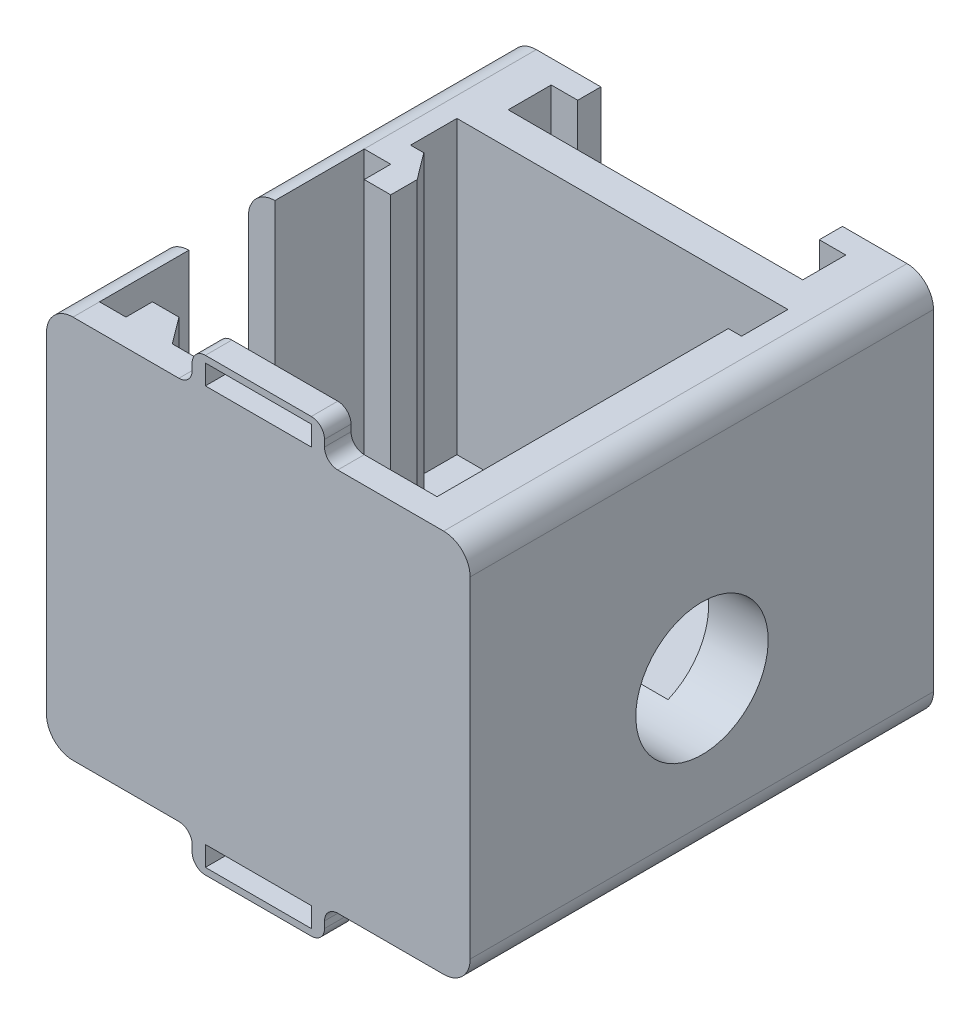
from build123d import *

# Parameters (mm, degrees)
SKETCH1_W                = 32
SKETCH1_H                = 29
BOSS_EXTRUDE1_DEPTH      = 35
FILLET1_R                = 2
SLOT_FOR_COIL_DEPTH      = 1
SLOT_FOR_COIL_DEPTH_BACK = 30
BOSS_EXTRUDE2_DEPTH      = 7
BOSS_EXTRUDE3_DEPTH      = 1.75
SKETCH5_W                = 2
SKETCH5_H                = 7
CUT_EXTRUDE2_DEPTH       = 33
CUT_EXTRUDE3_DEPTH       = 22
SKETCH7_W                = 2
SKETCH7_H                = 33
BOSS_EXTRUDE4_DEPTH      = 0.25
FILLET2_R                = 6
CUT_EXTRUDE5_DEPTH       = 4.5
SKETCH14_W               = 2.5
SKETCH14_H               = 20
CUT_EXTRUDE6_DEPTH       = 22
SKETCH16_W               = 2
SKETCH16_H               = 2
BOSS_EXTRUDE5_DEPTH      = 22
BOSS_EXTRUDE6_DEPTH      = 22
SKETCH21_W               = 10
SKETCH21_H               = 2
BOSS_EXTRUDE7_DEPTH      = 2.5
SKETCH23_W               = 8
SKETCH23_H               = 1.5
CUT_EXTRUDE7_DEPTH       = 2
FILLET3_R                = 1
CUT_EXTRUDE8_REACH       = 34
SKETCH26_R               = 5


with BuildPart() as part:
    # Sketch1 → Boss-Extrude1 (new body)
    with BuildSketch(Plane.XY):
        Rectangle(SKETCH1_W, SKETCH1_H)
    extrude(amount=BOSS_EXTRUDE1_DEPTH)

    # Fillet1
    fillet1_edges = [part.edges().sort_by_distance(p)[0] for p in [
        (16, -14.5, 17.5),
        (-16, -14.5, 17.5),
        (-16, 14.5, 17.5),
        (16, 14.5, 17.5),
    ]]
    fillet(fillet1_edges, radius=FILLET1_R)

    # Sketch2 → Slot for Coil (cut, two sides)
    with BuildSketch(Plane.XZ.offset(14.5)) as slot_for_coil_sk:
        Polygon((-9.125, 0), (-9.125, 1.75), (-11.125, 1.75), (-11.125, 5), (11.125, 5), (11.125, 1.75), (9.125, 1.75), (9.125, 0), align=None)
    extrude(amount=SLOT_FOR_COIL_DEPTH, mode=Mode.SUBTRACT)
    extrude(slot_for_coil_sk.sketch, amount=-SLOT_FOR_COIL_DEPTH_BACK, mode=Mode.SUBTRACT)

    # Sketch3 → Boss-Extrude2 (add)
    with BuildSketch(Plane.XZ.offset(14.5)):
        Polygon((-9.125, 0), (-9.125, 1.75), (-11.125, 1.75), (-11.125, 5), (11.125, 5), (11.125, 1.75), (9.125, 1.75), (9.125, 0), align=None)
    extrude(amount=-BOSS_EXTRUDE2_DEPTH)

    # Sketch4 → Boss-Extrude3 (add)
    with BuildSketch(Plane(origin=(0, 0, 1.75), x_dir=(-1, 0, 0), z_dir=(0, 0, -1))):
        with BuildLine():
            Line((-9.125, 7.5), (-9.125, 6.5))
            ThreePointArc((-9.125, 6.5), (-8.875, 7), (-9.125, 7.5))
        make_face()
    boss_extrude3 = extrude(amount=BOSS_EXTRUDE3_DEPTH)

    # Mirror1: Boss-Extrude3 across plane
    add(boss_extrude3.mirror(Plane(origin=(0, 0, 0), x_dir=(0, 0, 1), z_dir=(1, 0, 0))))

    # Sketch5 → Cut-Extrude2 (cut)
    with BuildSketch(Plane(origin=(0, 0, 0), x_dir=(-1, 0, 0), z_dir=(0, 0, -1))):
        with Locations((0, -11)):
            Rectangle(SKETCH5_W, SKETCH5_H)
    extrude(amount=-CUT_EXTRUDE2_DEPTH, mode=Mode.SUBTRACT)

    # Sketch6 → Cut-Extrude3 (cut)
    with BuildSketch(Plane(origin=(0, 14.5, 0), x_dir=(1, 0, 0), z_dir=(0, 1, 0))):
        Polygon((-12.5, -7.5), (-12.5, -11), (-11.5, -11), (-11.5, -33), (11.5, -33), (11.5, -11), (12.5, -11), (12.5, -7.5), align=None)
    extrude(amount=-CUT_EXTRUDE3_DEPTH, mode=Mode.SUBTRACT)

    # Sketch7 → Boss-Extrude4 (add)
    with BuildSketch(Plane.XZ.offset(14.5)):
        with Locations((0, 16.5)):
            Rectangle(SKETCH7_W, SKETCH7_H)
    extrude(amount=-BOSS_EXTRUDE4_DEPTH)

    # Fillet2
    fillet2_edges = [part.edges().sort_by_distance(p)[0] for p in [
        (0, -14.25, 33),
    ]]
    fillet(fillet2_edges, radius=FILLET2_R)

    # Sketch11 → Cut-Extrude5 (cut)
    with BuildSketch(Plane(origin=(-16, 0, 44), x_dir=(0, 0, -1), z_dir=(1, 0, 0))):
        with BuildLine():
            Line((24.25, 25), (24.25, 0))
            ThreePointArc((24.25, 0), (21, -3.25), (17.75, 0))
            Line((17.75, 0), (17.75, 25))
            ThreePointArc((17.75, 25), (21, 28.25), (24.25, 25))
        make_face()
    extrude(amount=CUT_EXTRUDE5_DEPTH, mode=Mode.SUBTRACT)

    # Sketch14 → Cut-Extrude6 (cut)
    with BuildSketch(Plane(origin=(0, 14.5, 0), x_dir=(1, 0, 0), z_dir=(0, 1, 0))):
        with Locations((-12.75, -23)):
            Rectangle(SKETCH14_W, SKETCH14_H)
    extrude(amount=-CUT_EXTRUDE6_DEPTH, mode=Mode.SUBTRACT)

    # Sketch16 → Boss-Extrude5 (add)
    with BuildSketch(Plane(origin=(0, 14.5, 0), x_dir=(1, 0, 0), z_dir=(0, 1, 0))):
        with Locations((-11, -14)):
            Rectangle(SKETCH16_W, SKETCH16_H)
        with Locations((-11, -32)):
            Rectangle(SKETCH16_W, SKETCH16_H)
    extrude(amount=-BOSS_EXTRUDE5_DEPTH)

    # Sketch20 → Boss-Extrude6 (add)
    with BuildSketch(Plane(origin=(0, 14.5, 0), x_dir=(1, 0, 0), z_dir=(0, 1, 0))):
        Polygon((-11.5, -11), (-10, -13), (-11.5, -13), align=None)
        Polygon((-10, -31), (-8.5, -33), (-10, -33), align=None)
    extrude(amount=-BOSS_EXTRUDE6_DEPTH)

    # Sketch21 → Boss-Extrude7 (add)
    with BuildSketch(Plane(origin=(0, 14.5, 0), x_dir=(-1, 0, 0), z_dir=(0, 1, 0))):
        with Locations((0, 34)):
            Rectangle(SKETCH21_W, SKETCH21_H)
    boss_extrude7 = extrude(amount=BOSS_EXTRUDE7_DEPTH)

    # Sketch23 → Cut-Extrude7 (cut)
    with BuildSketch(Plane.XY.offset(35)):
        with Locations((0, 15.75)):
            Rectangle(SKETCH23_W, SKETCH23_H)
    cut_extrude7 = extrude(amount=-CUT_EXTRUDE7_DEPTH, mode=Mode.SUBTRACT)

    # Mirror3: Boss-Extrude7, Cut-Extrude7 across plane
    add(boss_extrude7.mirror(Plane.ZX))
    add(cut_extrude7.mirror(Plane.ZX), mode=Mode.SUBTRACT)

    # Fillet3
    fillet3_edges = [part.edges().sort_by_distance(p)[0] for p in [
        (5, 14.5, 34),
        (-5, 14.5, 34),
        (5, 17, 34),
        (-5, 17, 34),
        (5, -17, 34),
        (-5, -17, 34),
        (5, -14.5, 34),
        (-5, -14.5, 34),
    ]]
    fillet(fillet3_edges, radius=FILLET3_R)

    # Sketch26 → Cut-Extrude8 (cut, up to next)
    with BuildSketch(Plane(origin=(16, 0, 0), x_dir=(0, 0, -1), z_dir=(1, 0, 0)), mode=Mode.PRIVATE) as cut_extrude8_sk1:
        with Locations((-17.485, -2.89)):
            Circle(SKETCH26_R)
    cut_extrude8_tool1 = extrude(cut_extrude8_sk1.sketch, amount=-CUT_EXTRUDE8_REACH, mode=Mode.PRIVATE) & part.part
    add(cut_extrude8_tool1.solids().sort_by_distance((16, -2.89, 17.485))[0], mode=Mode.SUBTRACT)


solid = part.part
